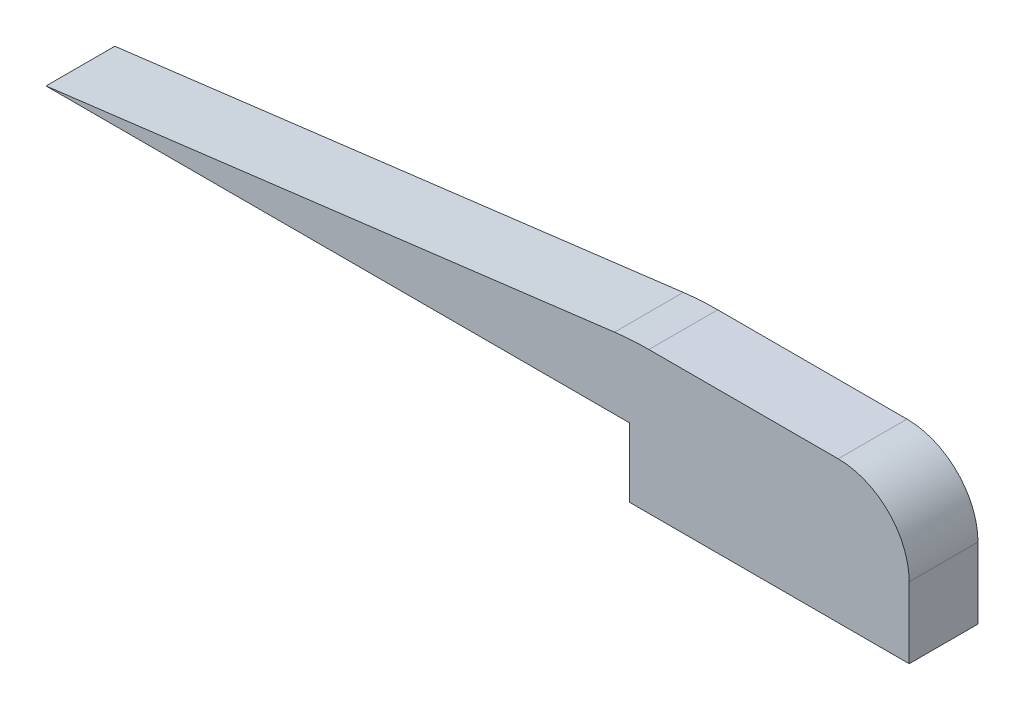
from build123d import *

# Parameters (mm, degrees)
BOSS_EXTRUDE1_DEPTH = 3.175


with BuildPart() as part:
    # Sketch1 → Boss-Extrude1 (new body)
    with BuildSketch(Plane.XY):
        with BuildLine():
            Line((38.2016, 0), (38.2016, -3.2766))
            Line((38.2016, -3.2766), (25.2984, -3.2766))
            Line((25.2984, -3.2766), (25.2984, -0.1016))
            Line((25.2984, -0.1016), (-1.631925387, -0.1016))
            Line((-1.631925387, -0.1016), (24.602830345, 3.177744467))
            ThreePointArc((24.602830345, 3.177744467), (25.395214732, 3.251862215), (26.190673403, 3.2766))
            Line((26.190673403, 3.2766), (34.925, 3.2766))
            ThreePointArc((34.925, 3.2766), (37.241906079, 2.316906079), (38.2016, 0))
        make_face()
    extrude(amount=BOSS_EXTRUDE1_DEPTH)


solid = part.part
